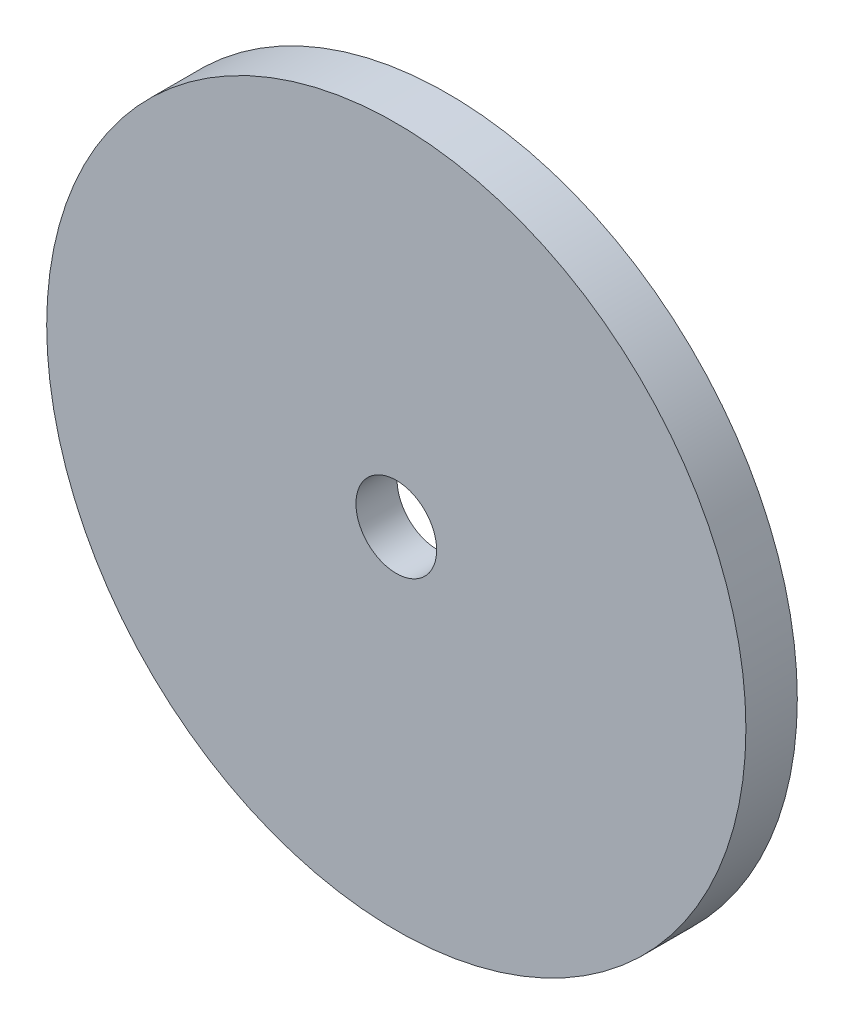
from build123d import *

# Parameters (mm, degrees)
SKETCH3_R           = 34
SKETCH3_R_2         = 10.9
BOSS_EXTRUDE2_DEPTH = 1
SKETCH4_R           = 34
SKETCH4_R_2         = 3.925
BOSS_EXTRUDE3_DEPTH = 4


with BuildPart() as part:
    # Sketch3 → Boss-Extrude2 (new body)
    with BuildSketch(Plane.XY):
        with Locations((9.62, 10)):
            Circle(SKETCH3_R)
        with Locations((9.62, 10)):
            Circle(SKETCH3_R_2, mode=Mode.SUBTRACT)
    extrude(amount=-BOSS_EXTRUDE2_DEPTH)

    # Sketch4 → Boss-Extrude3 (add)
    with BuildSketch(Plane.XY):
        with Locations((9.62, 10)):
            Circle(SKETCH4_R)
        with Locations((9.62, 10)):
            Circle(SKETCH4_R_2, mode=Mode.SUBTRACT)
    extrude(amount=BOSS_EXTRUDE3_DEPTH)


solid = part.part
